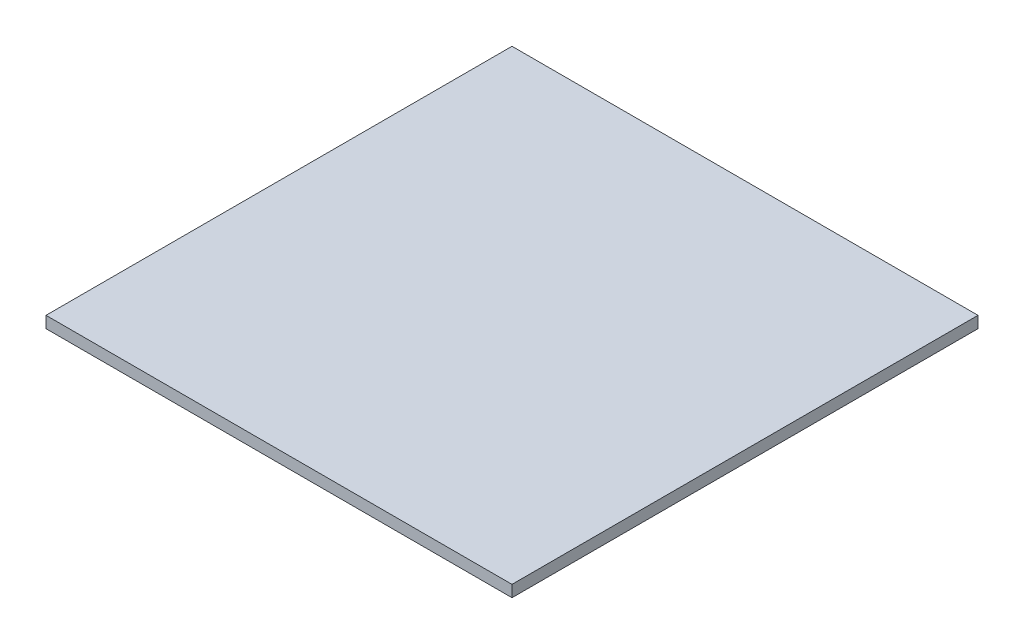
from build123d import *

# Parameters (mm, degrees)
SKETCH1_W           = 181
SKETCH1_H           = 181
BOSS_EXTRUDE1_DEPTH = 2.25


with BuildPart() as part:
    # Sketch1 → Boss-Extrude1 (new body, symmetric)
    with BuildSketch(Plane(origin=(0, 0, 0), x_dir=(1, 0, 0), z_dir=(0, 1, 0))):
        Rectangle(SKETCH1_W, SKETCH1_H)
    extrude(amount=BOSS_EXTRUDE1_DEPTH, both=True)


solid = part.part
